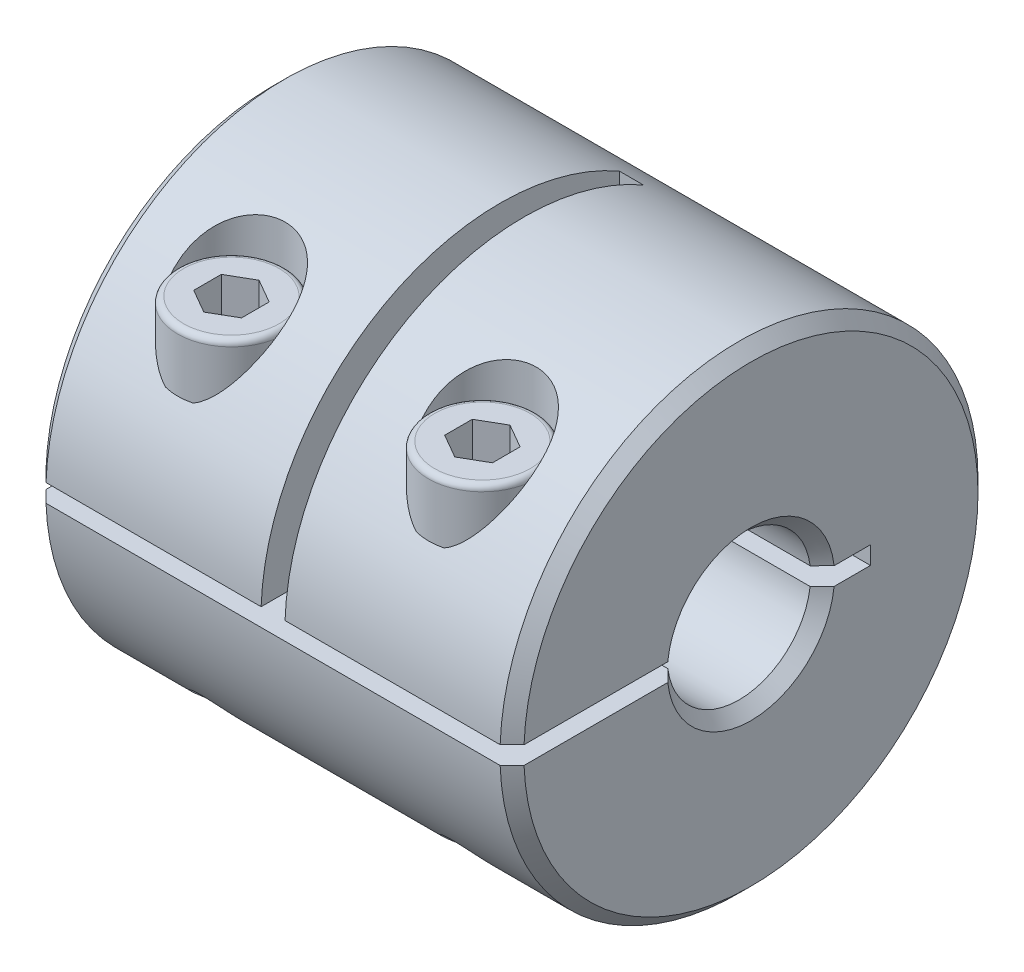
from build123d import *

# Parameters (mm, degrees)
SKETCH1_R           = 10
BOSS_EXTRUDE1_DEPTH = 10
SKETCH2_R           = 3
CUT_EXTRUDE1_DEPTH  = 21
CUT_EXTRUDE2_DEPTH  = 21
SKETCH6_W           = 1
SKETCH6_H           = 10.375
CUT_EXTRUDE3_DEPTH  = 15.992966276
CUT_EXTRUDE4_START  = -10.625
SKETCH7_R           = 1.25
CUT_EXTRUDE4_DEPTH  = 22
SKETCH8_R           = 2.25
CUT_EXTRUDE5_DEPTH  = 6.0000001
SKETCH9_R           = 2.25
BOSS_EXTRUDE2_DEPTH = 2.5
SKETCH10_R          = 1.25
BOSS_EXTRUDE3_DEPTH = 12.5
FILLET1_R           = 0.25
CUT_EXTRUDE6_DEPTH  = 2
CHAMFER1_SIZE       = 0.5


with BuildPart() as part:
    # Sketch1 → Boss-Extrude1 (new body, symmetric)
    with BuildSketch(Plane(origin=(0, 0, 0), x_dir=(0, 0, -1), z_dir=(1, 0, 0))):
        Circle(SKETCH1_R)
    extrude(amount=BOSS_EXTRUDE1_DEPTH, both=True)

    # Sketch2 → Cut-Extrude1 (cut, through all)
    with BuildSketch(Plane(origin=(10, 0, 0), x_dir=(0, 0, -1), z_dir=(1, 0, 0))):
        Circle(SKETCH2_R)
    extrude(amount=-CUT_EXTRUDE1_DEPTH, mode=Mode.SUBTRACT)

    # Sketch5 → Cut-Extrude2 (cut, through all)
    with BuildSketch(Plane(origin=(10, 0, 0), x_dir=(0, 0, -1), z_dir=(1, 0, 0))):
        with BuildLine():
            Line((-9.992966276, 0.375), (5, 0.375))
            Line((5, 0.375), (5, -0.375))
            Line((5, -0.375), (-9.992966276, -0.375))
            ThreePointArc((-9.992966276, -0.375), (-10, 0), (-9.992966276, 0.375))
        make_face()
    extrude(amount=-CUT_EXTRUDE2_DEPTH, mode=Mode.SUBTRACT)

    # Sketch6 → Cut-Extrude3 (cut, through all)
    with BuildSketch(Plane.XY.offset(-5)):
        with Locations((0, 4.8125)):
            Rectangle(SKETCH6_W, SKETCH6_H)
    extrude(amount=CUT_EXTRUDE3_DEPTH, mode=Mode.SUBTRACT)

    # Sketch7 → Cut-Extrude4 (cut)
    with BuildSketch(Plane(origin=(0, -0.375, 0), x_dir=(1, 0, 0), z_dir=(0, 1, 0)).offset(CUT_EXTRUDE4_START)):
        with Locations(Location((5.25, -6.484718251, 0), (0, 0, 270))):  # turned: the seam where the file's is
            Circle(SKETCH7_R)
    cut_extrude4 = extrude(amount=CUT_EXTRUDE4_DEPTH, mode=Mode.SUBTRACT)

    # Sketch8 → Cut-Extrude5 (cut, through all)
    with BuildSketch(Plane(origin=(0, 5, 0), x_dir=(-1, 0, 0), z_dir=(0, 1, 0))):
        with Locations((-5.25, 6.484718251)):
            Circle(SKETCH8_R)
    cut_extrude5 = extrude(amount=CUT_EXTRUDE5_DEPTH, mode=Mode.SUBTRACT)

    # Mirror1: Cut-Extrude4, Cut-Extrude5 across plane
    add(cut_extrude4.mirror(Plane(origin=(0, 0, 0), x_dir=(0, 0, 1), z_dir=(1, 0, 0))), mode=Mode.SUBTRACT)
    add(cut_extrude5.mirror(Plane(origin=(0, 0, 0), x_dir=(0, 0, 1), z_dir=(1, 0, 0))), mode=Mode.SUBTRACT)

    # Chamfer1
    chamfer1_edges = [part.edges().sort_by_distance(p)[0] for p in [
        (-10, -3, 0),
        (10, -3, 0),
        (-10, 0, -10),
        (10, 0, -10),
        (-10, 3, 0),
        (10, 3, 0),
    ]]
    chamfer(chamfer1_edges, length=CHAMFER1_SIZE)


with BuildPart() as body_2:
    # Sketch9 → Boss-Extrude2 (new body)
    with BuildSketch(Plane(origin=(0, 5, 0), x_dir=(1, 0, 0), z_dir=(0, 1, 0))):
        with Locations(Location((5.25, -6.484718251, 0), (0, 0, 270))):  # turned: the seam where the file's is
            Circle(SKETCH9_R)
    extrude(amount=BOSS_EXTRUDE2_DEPTH)

    # Sketch10 → Boss-Extrude3 (add)
    with BuildSketch(Plane(origin=(0, 7.5, 0), x_dir=(1, 0, 0), z_dir=(0, 1, 0))):
        with Locations(Location((5.25, -6.484718251, 0), (0, 0, 270))):  # turned: the seam where the file's is
            Circle(SKETCH10_R)
    extrude(amount=-BOSS_EXTRUDE3_DEPTH)

    # Fillet1
    fillet1_edges = [body_2.edges().sort_by_distance(p)[0] for p in [
        (5.25, 7.5, 4.234718251),
        (5.25, -5, 5.234718251),
    ]]
    fillet(fillet1_edges, radius=FILLET1_R)

    # Sketch11 → Cut-Extrude6 (cut)
    with BuildSketch(Plane(origin=(0, 7.5, 0), x_dir=(1, 0, 0), z_dir=(0, 1, 0))):
        Polygon((5.25, -5.330017712), (4.25, -5.907367981), (4.25, -7.06206852), (5.25, -7.639418789), (6.25, -7.06206852), (6.25, -5.907367981), align=None)
    extrude(amount=-CUT_EXTRUDE6_DEPTH, mode=Mode.SUBTRACT)


with BuildPart() as body_3:
    # Mirror2: mirrored copy
    add(body_2.part.mirror(Plane(origin=(0, 0, 0), x_dir=(0, 0, 1), z_dir=(1, 0, 0))))


solid = Compound([part.part, body_2.part, body_3.part])
